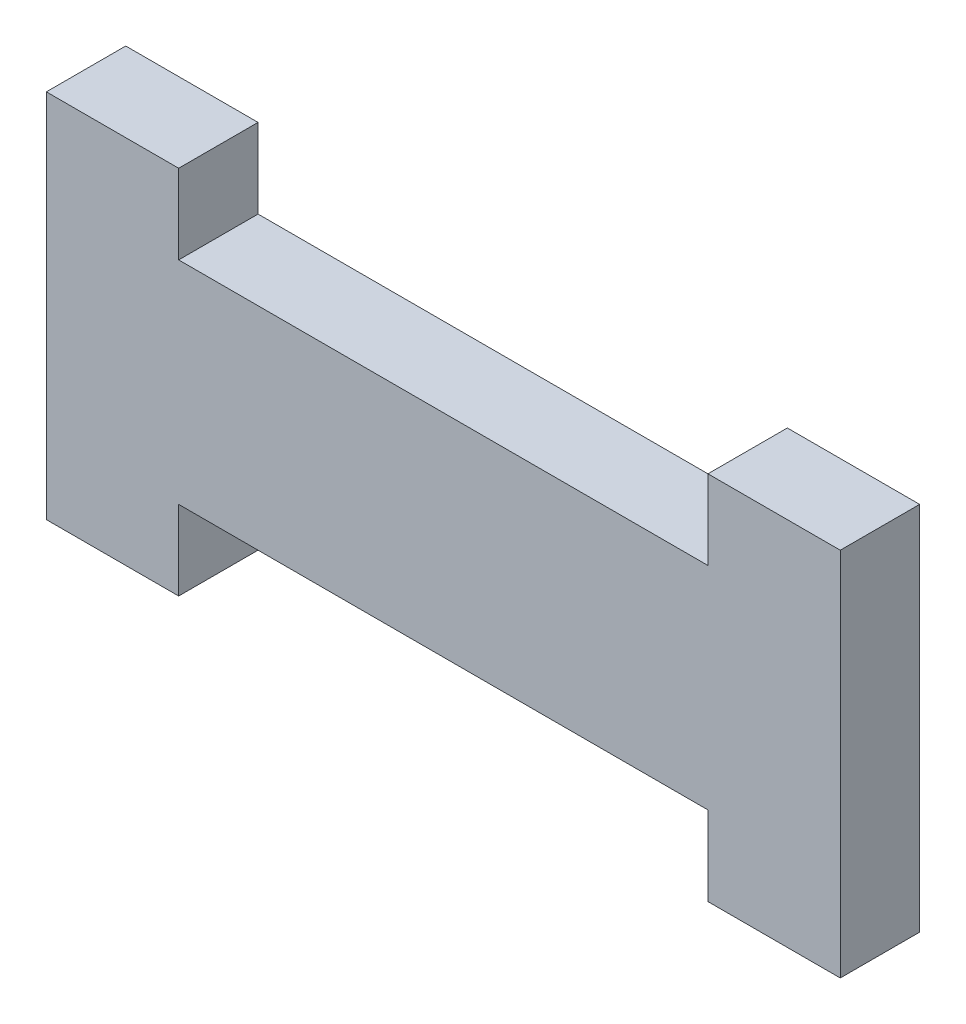
from build123d import *

# Parameters (mm, degrees)
BOSS_EXTRUDE1_DEPTH = 6


with BuildPart() as part:
    # Sketch1 → Boss-Extrude1 (new body)
    with BuildSketch(Plane.XY):
        Polygon((0, 0), (10, 0), (10, 6), (50, 6), (50, 0), (60, 0), (60, 28), (50, 28), (50, 22), (10, 22), (10, 28), (0, 28), align=None)
    extrude(amount=BOSS_EXTRUDE1_DEPTH)


solid = part.part
